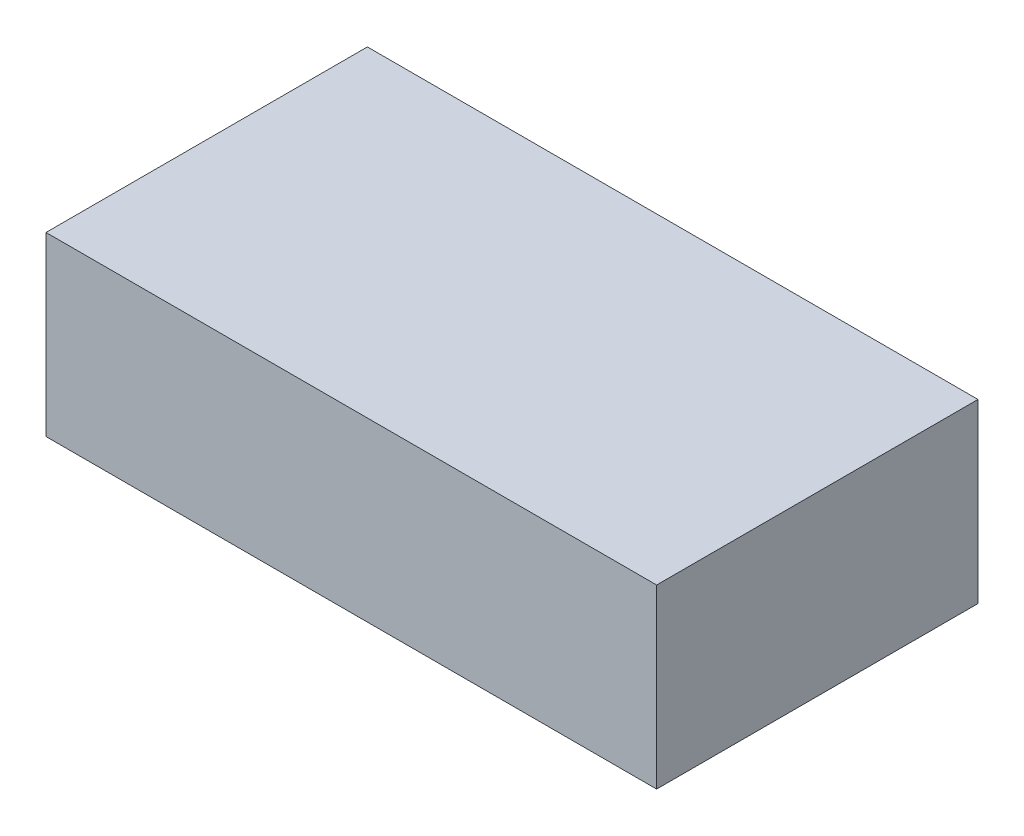
from build123d import *

# Parameters (mm, degrees)
ESQUISSE1_W        = 76
ESQUISSE1_H        = 40
BOSS_EXTRU_1_DEPTH = 22


with BuildPart() as part:
    # Esquisse1 → Boss.-Extru.1 (new body)
    with BuildSketch(Plane(origin=(0, 0, 0), x_dir=(1, 0, 0), z_dir=(0, 1, 0))):
        with Locations((-38, -20)):
            Rectangle(ESQUISSE1_W, ESQUISSE1_H)
    extrude(amount=BOSS_EXTRU_1_DEPTH)


solid = part.part
